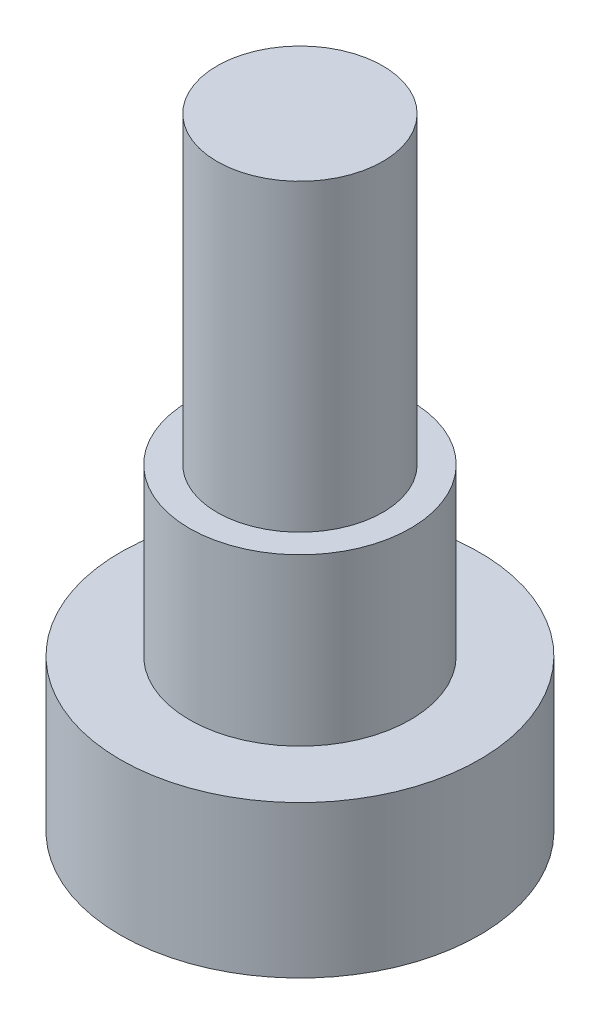
from build123d import *

# Parameters (mm, degrees)
SKETCH_1_R      = 6.5
EXTRUDE_1_DEPTH = 5.5
SKETCH_2_R      = 4
EXTRUDE_2_DEPTH = 6
SKETCH_3_R      = 3
EXTRUDE_3_DEPTH = 11


with BuildPart() as part:
    # 草图1 → 凸台-拉伸1 (new body)
    with BuildSketch(Plane(origin=(0, 0, 0), x_dir=(1, 0, 0), z_dir=(0, 1, 0))):
        Circle(SKETCH_1_R)
    extrude(amount=EXTRUDE_1_DEPTH)

    # 草图2 → 凸台-拉伸2 (add)
    with BuildSketch(Plane(origin=(0, 5.5, 0), x_dir=(1, 0, 0), z_dir=(0, 1, 0))):
        Circle(SKETCH_2_R)
    extrude(amount=EXTRUDE_2_DEPTH)

    # 草图3 → 凸台-拉伸3 (add)
    with BuildSketch(Plane(origin=(0, 11.5, 0), x_dir=(1, 0, 0), z_dir=(0, 1, 0))):
        Circle(SKETCH_3_R)
    extrude(amount=EXTRUDE_3_DEPTH)


solid = part.part
